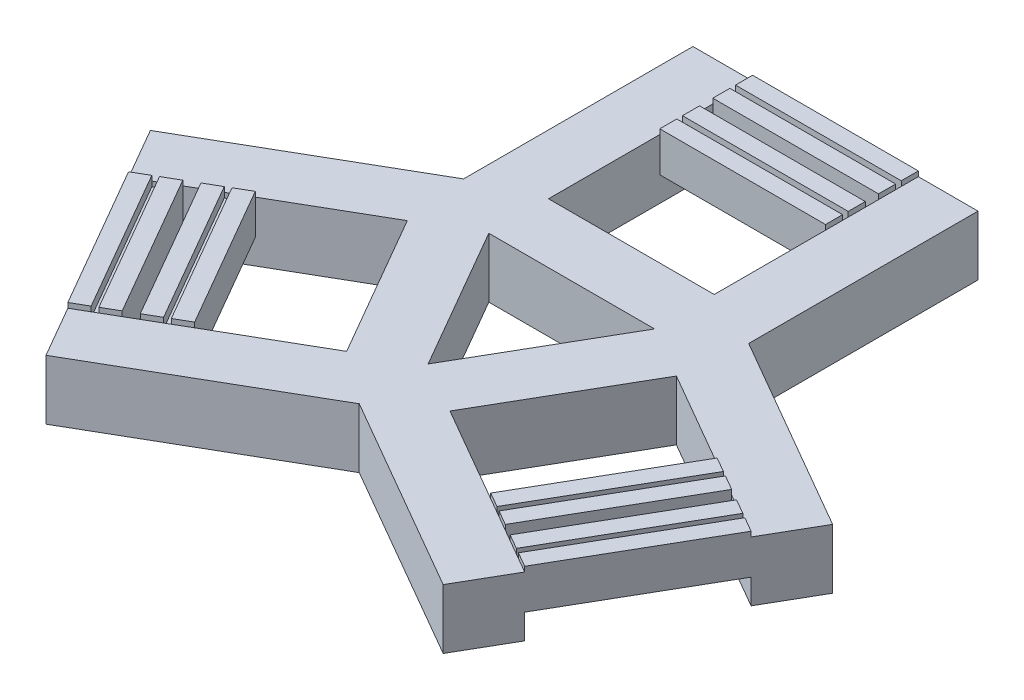
from build123d import *

# Parameters (mm, degrees)
SALIENTE_EXTRUIR1_DEPTH   = 15
SALIENTE_EXTRUIR1_2_DEPTH = 15
SALIENTE_EXTRUIR1_3_DEPTH = 15
SALIENTE_EXTRUIR1_4_DEPTH = 15
SALIENTE_EXTRUIR1_5_DEPTH = 15
SALIENTE_EXTRUIR1_6_DEPTH = 15
CROQUIS1_4_W              = 250
CROQUIS1_4_H              = 25.75
SALIENTE_EXTRUIR2_DEPTH   = 30
SALIENTE_EXTRUIR3_DEPTH   = 22.5
SALIENTE_EXTRUIR4_DEPTH   = 67.5


with BuildPart() as part:
    # Croquis1 → Saliente-Extruir1 (new, symmetric)
    with BuildSketch(Plane(origin=(0, 0, 0), x_dir=(1, 0, 0), z_dir=(0, 1, 0))):
        Polygon((-377.949753328, -73.871824527), (-315.449753328, -182.125), (-252.949753328, -290.378175473), (-245.588537396, -286.128175473), (-370.588537396, -69.621824527), align=None)
    extrude(amount=SALIENTE_EXTRUIR1_DEPTH, both=True)



with BuildPart() as body_2:
    # Croquis1 → Saliente-Extruir1 2 (new, symmetric)
    with BuildSketch(Plane(origin=(0, 0, 0), x_dir=(1, 0, 0), z_dir=(0, 1, 0))):
        Polygon((-314.870569699, -326.128175473), (-377.370569699, -217.875), (-439.870569699, -109.621824527), (-447.231785631, -113.871824527), (-322.231785631, -330.378175473), align=None)
    extrude(amount=SALIENTE_EXTRUIR1_2_DEPTH, both=True)


with BuildPart() as body_3:
    # Croquis1 → Saliente-Extruir1 3 (new, symmetric)
    with BuildSketch(Plane(origin=(0, 0, 0), x_dir=(1, 0, 0), z_dir=(0, 1, 0))):
        Polygon((-125, 364.25), (-125, 355.75), (125, 355.75), (125, 364.25), (0, 364.25), align=None)
    extrude(amount=SALIENTE_EXTRUIR1_3_DEPTH, both=True)


with BuildPart() as body_4:
    # Croquis1 → Saliente-Extruir1 4 (new, symmetric)
    with BuildSketch(Plane(origin=(0, 0, 0), x_dir=(1, 0, 0), z_dir=(0, 1, 0))):
        Polygon((370.588537396, -69.621824527), (245.588537396, -286.128175473), (252.949753328, -290.378175473), (315.449753328, -182.125), (377.949753328, -73.871824527), align=None)
    extrude(amount=SALIENTE_EXTRUIR1_4_DEPTH, both=True)


with BuildPart() as body_5:
    # Croquis1 → Saliente-Extruir1 5 (new, symmetric)
    with BuildSketch(Plane(origin=(0, 0, 0), x_dir=(1, 0, 0), z_dir=(0, 1, 0))):
        Polygon((-125, 444.25), (-125, 435.75), (0, 435.75), (125, 435.75), (125, 444.25), align=None)
    extrude(amount=SALIENTE_EXTRUIR1_5_DEPTH, both=True)


with BuildPart() as body_6:
    # Croquis1 → Saliente-Extruir1 6 (new, symmetric)
    with BuildSketch(Plane(origin=(0, 0, 0), x_dir=(1, 0, 0), z_dir=(0, 1, 0))):
        Polygon((377.370569699, -217.875), (314.870569699, -326.128175473), (322.231785631, -330.378175473), (447.231785631, -113.871824527), (439.870569699, -109.621824527), align=None)
    extrude(amount=SALIENTE_EXTRUIR1_6_DEPTH, both=True)


with BuildPart() as part_1:
    add(part.part)

    add(body_2.part)  # Saliente-Extruir2 merges body 2

    add(body_3.part)  # Saliente-Extruir2 merges body 3

    add(body_4.part)  # Saliente-Extruir2 merges body 4

    add(body_5.part)  # Saliente-Extruir2 merges body 5

    add(body_6.part)  # Saliente-Extruir2 merges body 6
    # Croquis1_4 → Saliente-Extruir2 (add, symmetric)
    with BuildSketch(Plane(origin=(0, 0, 0), x_dir=(1, 0, 0), z_dir=(0, 1, 0))):
        Polygon((-252.949753328, -290.378175473), (-377.949753328, -73.871824527), (-400.249907476, -86.746824527), (-275.249907476, -303.253175473), align=None)
        Polygon((-292.570415552, -313.253175473), (-417.570415552, -96.746824527), (-439.870569699, -109.621824527), (-314.870569699, -326.128175473), align=None)
        Polygon((-348.288383249, -56.746824527), (-370.588537396, -69.621824527), (-245.588537396, -286.128175473), (-223.288383249, -273.253175473), align=None)
        Polygon((-322.231785631, -330.378175473), (-447.231785631, -113.871824527), (-469.531939779, -126.746824527), (-344.531939779, -343.253175473), align=None)
        with Locations((0, 342.875)):
            Rectangle(CROQUIS1_4_W, CROQUIS1_4_H)
        Polygon((348.288383249, -56.746824527), (223.288383249, -273.253175473), (245.588537396, -286.128175473), (370.588537396, -69.621824527), align=None)
        with Locations((0, 377.125)):
            Rectangle(CROQUIS1_4_W, CROQUIS1_4_H)
        Polygon((252.949753328, -290.378175473), (275.249907476, -303.253175473), (400.249907476, -86.746824527), (377.949753328, -73.871824527), align=None)
        with Locations((0, 422.875)):
            Rectangle(CROQUIS1_4_W, CROQUIS1_4_H)
        Polygon((292.570415552, -313.253175473), (314.870569699, -326.128175473), (439.870569699, -109.621824527), (417.570415552, -96.746824527), align=None)
        with Locations((0, 457.125)):
            Rectangle(CROQUIS1_4_W, CROQUIS1_4_H)
        Polygon((322.231785631, -330.378175473), (344.531939779, -343.253175473), (469.531939779, -126.746824527), (447.231785631, -113.871824527), align=None)
    extrude(amount=SALIENTE_EXTRUIR2_DEPTH, both=True)

    # Croquis1_5 → Saliente-Extruir3 (add)
    with BuildSketch(Plane(origin=(0, 0, 0), x_dir=(1, 0, 0), z_dir=(0, 1, 0))):
        Polygon((-202.942286341, 27.168783649), (-77.942286341, -189.337567297), (-344.531939779, -343.253175473), (-299.531939779, -421.195461814), (0, -248.260615752), (299.531939779, -421.195461814), (344.531939779, -343.253175473), (77.942286341, -189.337567297), (202.942286341, 27.168783649), (469.531939779, -126.746824527), (514.531939779, -48.804538186), (215, 124.130307876), (215, 470), (125, 470), (125, 162.168783649), (-125, 162.168783649), (-125, 470), (-215, 470), (-215, 124.130307876), (-514.531939779, -48.804538186), (-469.531939779, -126.746824527), align=None)
        Polygon((-125, 72.168783649), (125, 72.168783649), (0, -144.337567297), align=None, mode=Mode.SUBTRACT)
    extrude(amount=SALIENTE_EXTRUIR3_DEPTH)

    # Croquis1_6 → Saliente-Extruir4 (add)
    with BuildSketch(Plane(origin=(0, 0, 0), x_dir=(1, 0, 0), z_dir=(0, 1, 0))):
        Polygon((-202.942286341, 27.168783649), (-77.942286341, -189.337567297), (-344.531939779, -343.253175473), (-299.531939779, -421.195461814), (0, -248.260615752), (299.531939779, -421.195461814), (344.531939779, -343.253175473), (77.942286341, -189.337567297), (202.942286341, 27.168783649), (469.531939779, -126.746824527), (514.531939779, -48.804538186), (215, 124.130307876), (215, 470), (125, 470), (125, 162.168783649), (-125, 162.168783649), (-125, 470), (-215, 470), (-215, 124.130307876), (-514.531939779, -48.804538186), (-469.531939779, -126.746824527), align=None)
        Polygon((-125, 72.168783649), (125, 72.168783649), (0, -144.337567297), align=None, mode=Mode.SUBTRACT)
    extrude(amount=-SALIENTE_EXTRUIR4_DEPTH)


solid = part_1.part
